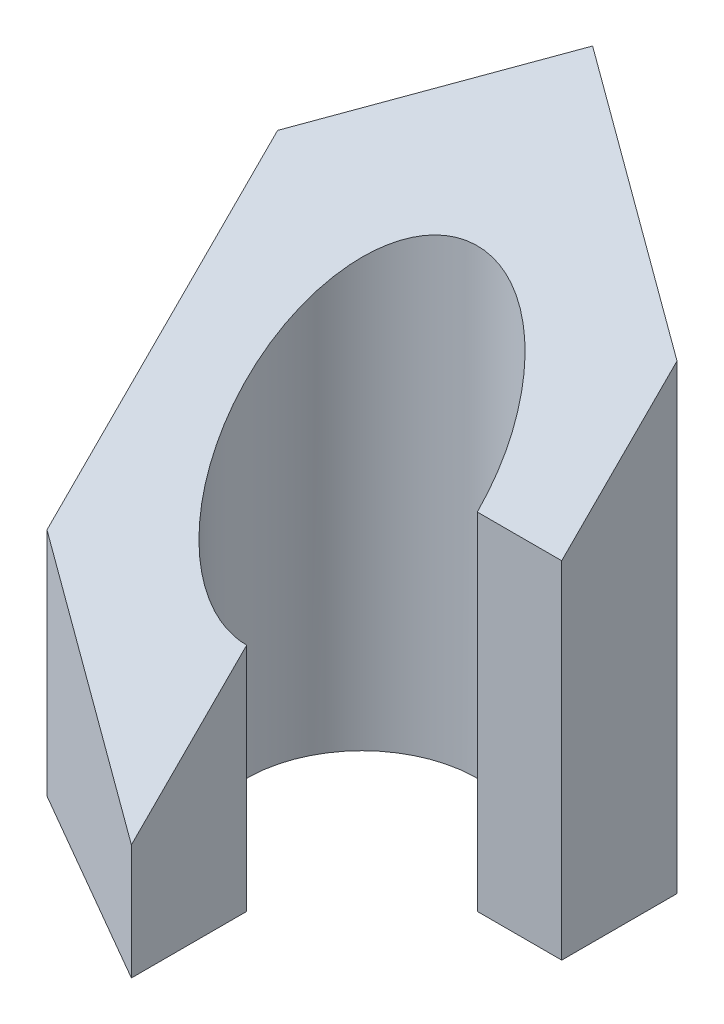
from build123d import *

# Parameters (mm, degrees)
BOSS_EXTRUDE1_DEPTH     = 10
CUT_EXTRUDE2_DEPTH      = 10
CUT_EXTRUDE2_DEPTH_BACK = 10


with BuildPart() as part:
    # Sketch1 → Boss-Extrude1 (new body)
    with BuildSketch(Plane(origin=(0, 0, 0), x_dir=(1, 0, 0), z_dir=(0, 1, 0))):
        with BuildLine():
            Line((2, 0), (3.464101615, 0))
            Line((3.464101615, 0), (3.464101615, 2))
            Line((3.464101615, 2), (0, 4))
            Line((0, 4), (-3.464101615, 2))
            Line((-3.464101615, 2), (-3.464101615, -2))
            Line((-3.464101615, -2), (0, -4))
            Line((0, -4), (0, -2))
            ThreePointArc((0, -2), (-1.414213562, 1.414213562), (2, 0))
        make_face()
    extrude(amount=BOSS_EXTRUDE1_DEPTH)

    # Sketch3 → Cut-Extrude2 (cut, two sides)
    with BuildSketch(Plane(origin=(0, 0, 0), x_dir=(0, 0, -1), z_dir=(1, 0, 0))) as cut_extrude2_sk:
        Polygon((-4, 2), (4, 10), (-4, 10), align=None)
    extrude(amount=CUT_EXTRUDE2_DEPTH, mode=Mode.SUBTRACT)
    extrude(cut_extrude2_sk.sketch, amount=-CUT_EXTRUDE2_DEPTH_BACK, mode=Mode.SUBTRACT)


solid = part.part
